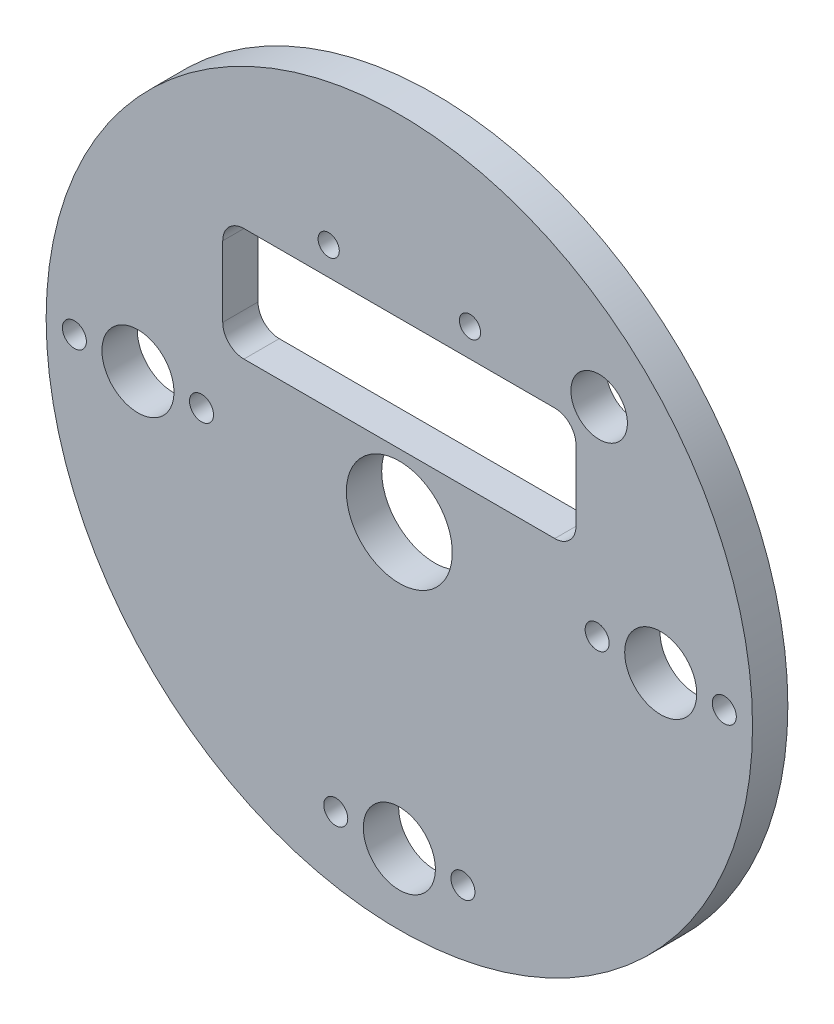
from build123d import *

# Parameters (mm, degrees)
SKETCH1_R                    = 50
BOSS_EXTRUDE1_DEPTH          = 5
F_15_0_15_DIAMETER_HOLE1_D   = 15
F_10_2_10_2_DIAMETER_HOLE1_D = 10.2
M3_CLEARANCE_HOLE1_D         = 3.4
CUT_EXTRUDE1_DEPTH           = 10
SKETCH10_R                   = 1.5
CUT_EXTRUDE2_DEPTH           = 10
SKETCH11_R                   = 4
CUT_EXTRUDE3_DEPTH           = 10


with BuildPart() as part:
    # Sketch1 → Boss-Extrude1 (new body)
    with BuildSketch(Plane.XY):
        Circle(SKETCH1_R)
    extrude(amount=BOSS_EXTRUDE1_DEPTH)

    # Ø15.0 (15) Diameter Hole1 (through all)
    with Locations(Plane(origin=(0, 0, 0), x_dir=(-1, 0, 0), z_dir=(0, 0, -1))):
        with Locations((0, 0)):
            Hole(F_15_0_15_DIAMETER_HOLE1_D / 2)

    # Ø10.2 (10.2) Diameter Hole1 (through all)
    with Locations(Plane(origin=(0, 0, 0), x_dir=(-1, 0, 0), z_dir=(0, 0, -1))):
        with Locations((37, 0), (-37, 0), (0, -40)):
            Hole(F_10_2_10_2_DIAMETER_HOLE1_D / 2)

    # M3 Clearance Hole1 (through all)
    with Locations(Plane.XY.offset(5)):
        with Locations((46, 0), (28, 0), (9, -40), (-9, -40), (-46, 0), (-28, 0)):
            Hole(M3_CLEARANCE_HOLE1_D / 2)

    # Sketch9 → Cut-Extrude1 (cut)
    with BuildSketch(Plane.XY.offset(5)):
        with BuildLine():
            Line((-22, 25), (22, 25))
            ThreePointArc((22, 25), (24.121320344, 24.121320344), (25, 22))
            Line((25, 22), (25, 12))
            ThreePointArc((25, 12), (24.121320344, 9.878679656), (22, 9))
            Line((22, 9), (-22, 9))
            ThreePointArc((-22, 9), (-24.121320344, 9.878679656), (-25, 12))
            Line((-25, 12), (-25, 22))
            ThreePointArc((-25, 22), (-24.121320344, 24.121320344), (-22, 25))
        make_face()
    extrude(amount=-CUT_EXTRUDE1_DEPTH, mode=Mode.SUBTRACT)

    # Sketch10 → Cut-Extrude2 (cut)
    with BuildSketch(Plane.XY.offset(5)):
        with Locations((-10, 29)):
            Circle(SKETCH10_R)
        with Locations((10, 29)):
            Circle(SKETCH10_R)
    extrude(amount=-CUT_EXTRUDE2_DEPTH, mode=Mode.SUBTRACT)

    # Sketch11 → Cut-Extrude3 (cut)
    with BuildSketch(Plane.XY.offset(5)):
        with Locations((28.284271247, 28.284271247)):
            Circle(SKETCH11_R)
    extrude(amount=-CUT_EXTRUDE3_DEPTH, mode=Mode.SUBTRACT)


solid = part.part
